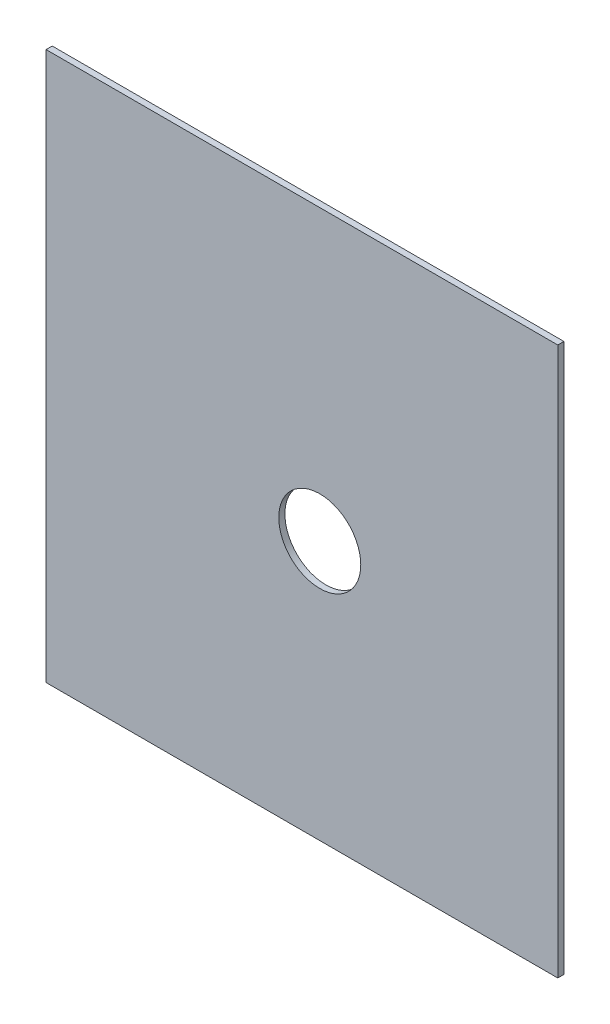
from build123d import *

# Parameters (mm, degrees)
SKETCH1_W           = 249.6
SKETCH1_H           = 267.4
BOSS_EXTRUDE1_DEPTH = 3
SKETCH2_R           = 20
CUT_EXTRUDE1_DEPTH  = 4


with BuildPart() as part:
    # Sketch1 → Boss-Extrude1 (new body)
    with BuildSketch(Plane.XY):
        with Locations((124.8, -133.7)):
            Rectangle(SKETCH1_W, SKETCH1_H)
    extrude(amount=BOSS_EXTRUDE1_DEPTH)

    # Sketch2 → Cut-Extrude1 (cut, through all)
    with BuildSketch(Plane.XY.offset(3)):
        with Locations((133.5, -140.910978413)):
            Circle(SKETCH2_R)
    extrude(amount=-CUT_EXTRUDE1_DEPTH, mode=Mode.SUBTRACT)


solid = part.part
